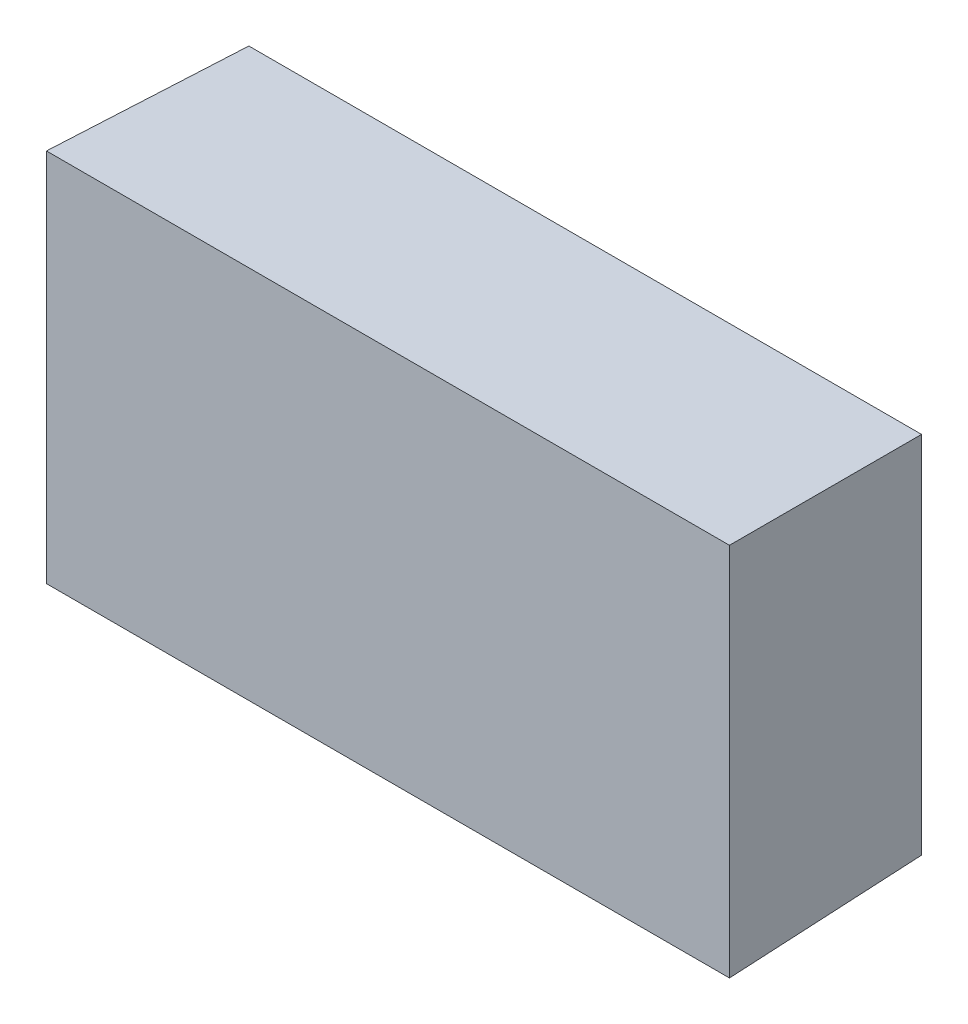
from build123d import *

# Parameters (mm, degrees)
SKETCH1_W           = 121.2
SKETCH1_H           = 66.5
BOSS_EXTRUDE1_DEPTH = 35
BOSS_EXTRUDE1_TAPER = 1.5


with BuildPart() as part:
    # Sketch1 → Boss-Extrude1 (new body)
    with BuildSketch(Plane.XY):
        Rectangle(SKETCH1_W, SKETCH1_H)
    extrude(amount=-BOSS_EXTRUDE1_DEPTH, taper=BOSS_EXTRUDE1_TAPER)


solid = part.part
